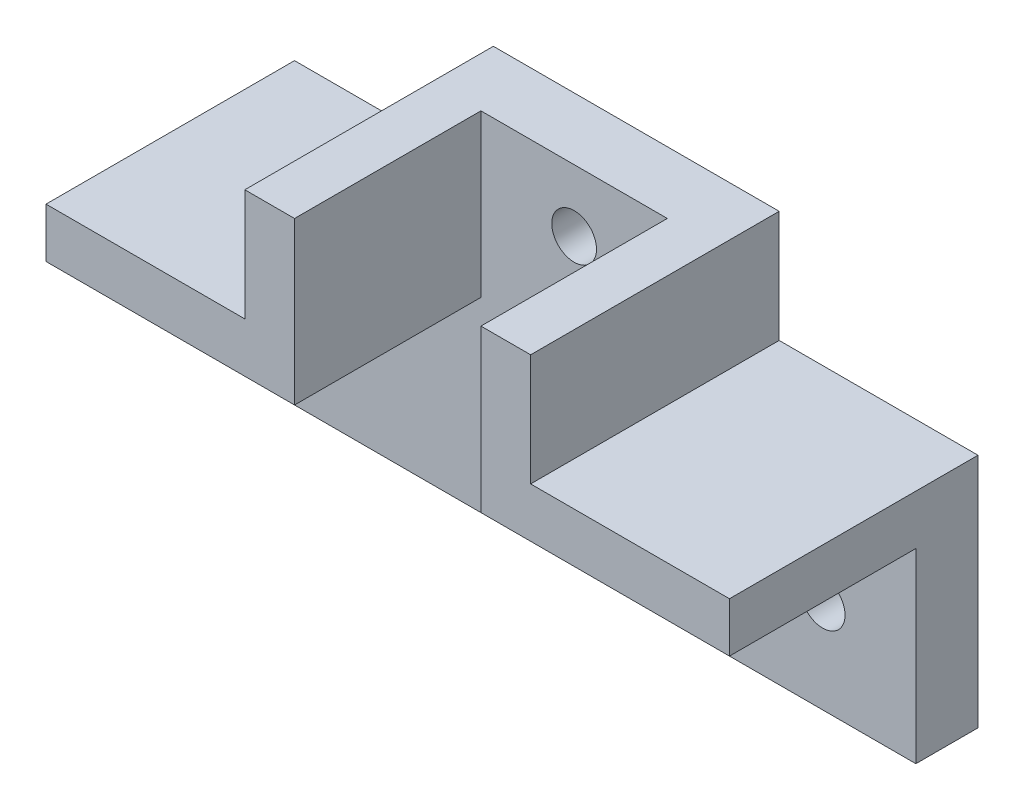
from build123d import *

# Parameters (mm, degrees)
BOSS_EXTRUDE1_DEPTH = 5
BOSS_EXTRUDE2_DEPTH = 20
SKETCH6_R           = 1.8
CUT_EXTRUDE3_DEPTH  = 6


with BuildPart() as part:
    # Sketch1 → Boss-Extrude1 (new body)
    with BuildSketch(Plane.XY):
        Polygon((14.31372549, 2.735294118), (34.31372549, 2.735294118), (34.31372549, -12.264705882), (-20.68627451, -12.264705882), (-20.68627451, 2.735294118), (-0.68627451, 2.735294118), (-0.68627451, 15.735294118), (14.31372549, 15.735294118), align=None)
    extrude(amount=BOSS_EXTRUDE1_DEPTH)

    # Sketch2 → Boss-Extrude2 (add)
    with BuildSketch(Plane(origin=(0, 0, 0), x_dir=(-1, 0, 0), z_dir=(0, 0, -1))):
        Polygon((0.68627451, 15.735294118), (4.68627451, 15.735294118), (4.68627451, 6.735294118), (6.079970528, 6.735294118), (20.68627451, 6.735294118), (20.68627451, 2.735294118), (0.68627451, 2.735294118), align=None)
    boss_extrude2 = extrude(amount=-BOSS_EXTRUDE2_DEPTH)

    # Mirror1: Boss-Extrude2 across plane
    add(boss_extrude2.mirror(Plane.ZY.offset(-6.81372549)))

    # Sketch6 → Cut-Extrude3 (cut, through all)
    with BuildSketch(Plane.XY.offset(5)):
        with Locations((6.81372549, 10.735294118)):
            Circle(SKETCH6_R)
        with Locations((-13.18627451, -4.764705882)):
            Circle(SKETCH6_R)
        with Locations((26.81372549, -4.764705882)):
            Circle(SKETCH6_R)
    extrude(amount=-CUT_EXTRUDE3_DEPTH, mode=Mode.SUBTRACT)


solid = part.part
